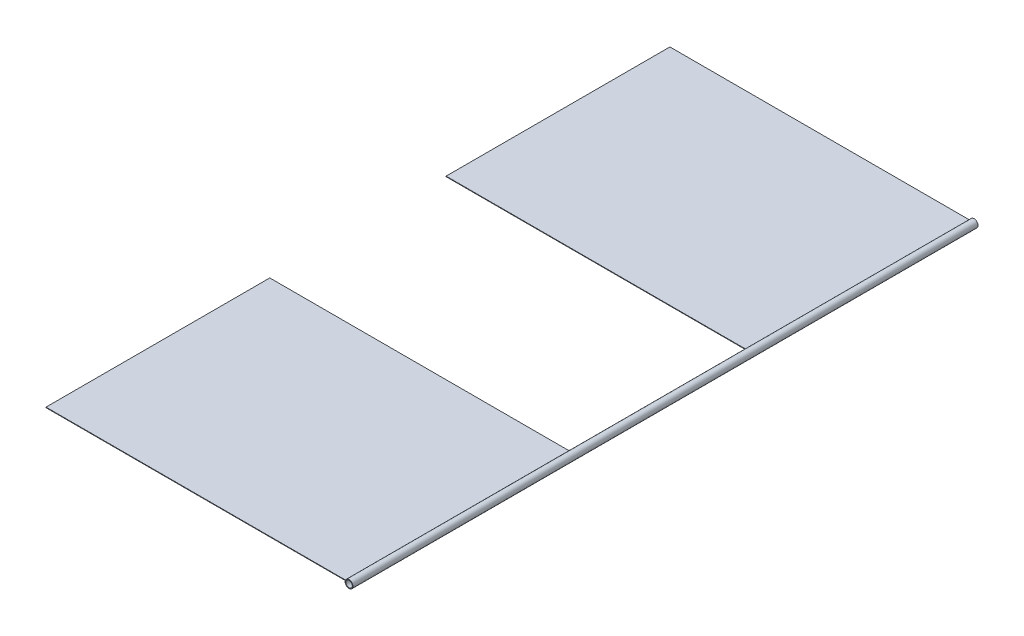
from build123d import *

# Parameters (mm, degrees)
SKETCH1_R           = 19.05
SKETCH1_R_2         = 15.875
BOSS_EXTRUDE1_DEPTH = 3048
SKETCH2_R           = 12.7
CUT_EXTRUDE1_DEPTH  = 20.05
SKETCH3_W           = 1467.580737964
SKETCH3_H           = 1091.209821844
SKETCH3_H_2         = 1091.209821843
BOSS_EXTRUDE2_DEPTH = 2.54


with BuildPart() as part:
    # Sketch1 → Boss-Extrude1 (new body)
    with BuildSketch(Plane.XY):
        Circle(SKETCH1_R)
        Circle(SKETCH1_R_2, mode=Mode.SUBTRACT)
    extrude(amount=BOSS_EXTRUDE1_DEPTH)

    # Sketch2 → Cut-Extrude1 (cut, through all)
    with BuildSketch(Plane(origin=(0, 0, 0), x_dir=(0, 0, -1), z_dir=(1, 0, 0))):
        with Locations((-1828.8, 0)):
            Circle(SKETCH2_R)
    extrude(amount=-CUT_EXTRUDE1_DEPTH, mode=Mode.SUBTRACT)

    # Sketch3 → Boss-Extrude2 (add)
    with BuildSketch(Plane(origin=(0, 0, 0), x_dir=(1, 0, 0), z_dir=(0, 1, 0))):
        with Locations((-749.665368982, -545.604910922)):
            Rectangle(SKETCH3_W, SKETCH3_H)
        with Locations((-749.665368982, -2496.684282285)):
            Rectangle(SKETCH3_W, SKETCH3_H_2)
    extrude(amount=BOSS_EXTRUDE2_DEPTH)


solid = part.part
